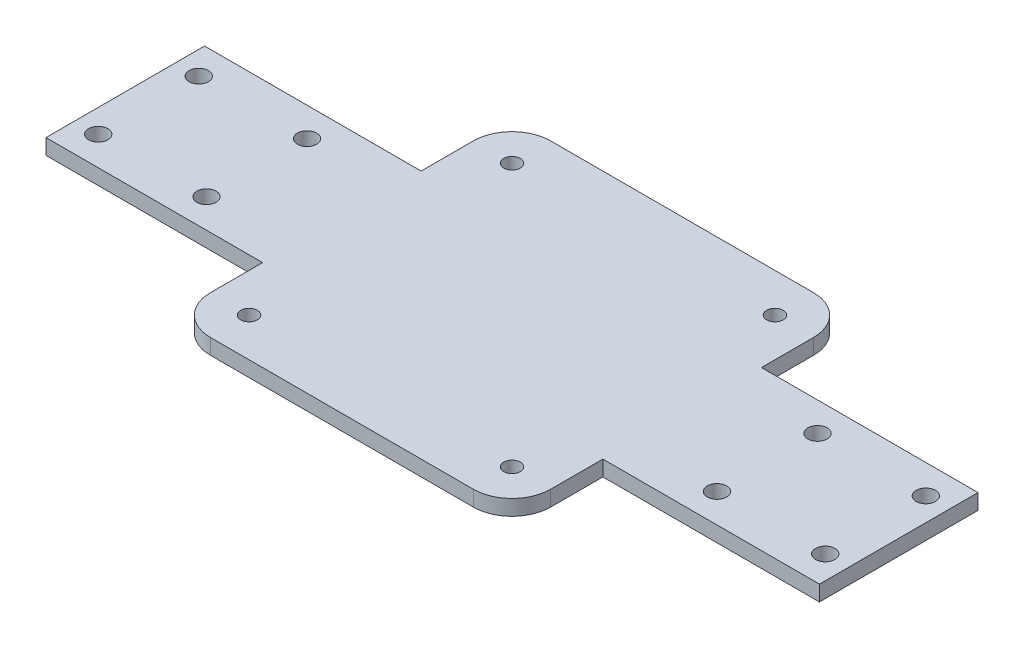
from build123d import *

# Parameters (mm, degrees)
SKETCH1_W           = 88
SKETCH1_H           = 88
BOSS_EXTRUDE1_DEPTH = 4
FILLET1_R           = 10
SKETCH2_R           = 2.15
CUT_EXTRUDE1_DEPTH  = 5
SKETCH3_W           = 200
SKETCH3_H           = 41
BOSS_EXTRUDE2_DEPTH = 4
SKETCH5_R           = 2.5
CUT_EXTRUDE2_DEPTH  = 5


with BuildPart() as part:
    # Sketch1 → Boss-Extrude1 (new body)
    with BuildSketch(Plane(origin=(0, 0, 0), x_dir=(1, 0, 0), z_dir=(0, 1, 0))):
        Rectangle(SKETCH1_W, SKETCH1_H)
    extrude(amount=BOSS_EXTRUDE1_DEPTH)

    # Fillet1
    fillet1_edges = [part.edges().sort_by_distance(p)[0] for p in [
        (-44, 2, -44),
        (44, 2, -44),
        (44, 2, 44),
        (-44, 2, 44),
    ]]
    fillet(fillet1_edges, radius=FILLET1_R)

    # Sketch2 → Cut-Extrude1 (cut, through all)
    with BuildSketch(Plane(origin=(0, 4, 0), x_dir=(1, 0, 0), z_dir=(0, 1, 0))):
        with Locations((34, 34)):
            Circle(SKETCH2_R)
        with Locations((-34, 34)):
            Circle(SKETCH2_R)
        with Locations((34, -34)):
            Circle(SKETCH2_R)
        with Locations((-34, -34)):
            Circle(SKETCH2_R)
    extrude(amount=-CUT_EXTRUDE1_DEPTH, mode=Mode.SUBTRACT)

    # Sketch3 → Boss-Extrude2 (add)
    with BuildSketch(Plane(origin=(0, 0, 0), x_dir=(1, 0, 0), z_dir=(0, 1, 0))):
        Rectangle(SKETCH3_W, SKETCH3_H)
    extrude(amount=BOSS_EXTRUDE2_DEPTH)

    # Sketch5 → Cut-Extrude2 (cut, through all)
    with BuildSketch(Plane.XZ):
        with Locations((-66, 13)):
            Circle(SKETCH5_R)
        with Locations((-66, -13)):
            Circle(SKETCH5_R)
        with Locations((-94, -13)):
            Circle(SKETCH5_R)
        with Locations((-94, 13)):
            Circle(SKETCH5_R)
    cut_extrude2 = extrude(amount=-CUT_EXTRUDE2_DEPTH, mode=Mode.SUBTRACT)

    # Mirror1: Cut-Extrude2 across plane
    add(cut_extrude2.mirror(Plane(origin=(0, 0, 0), x_dir=(0, 0, 1), z_dir=(1, 0, 0))), mode=Mode.SUBTRACT)


solid = part.part
